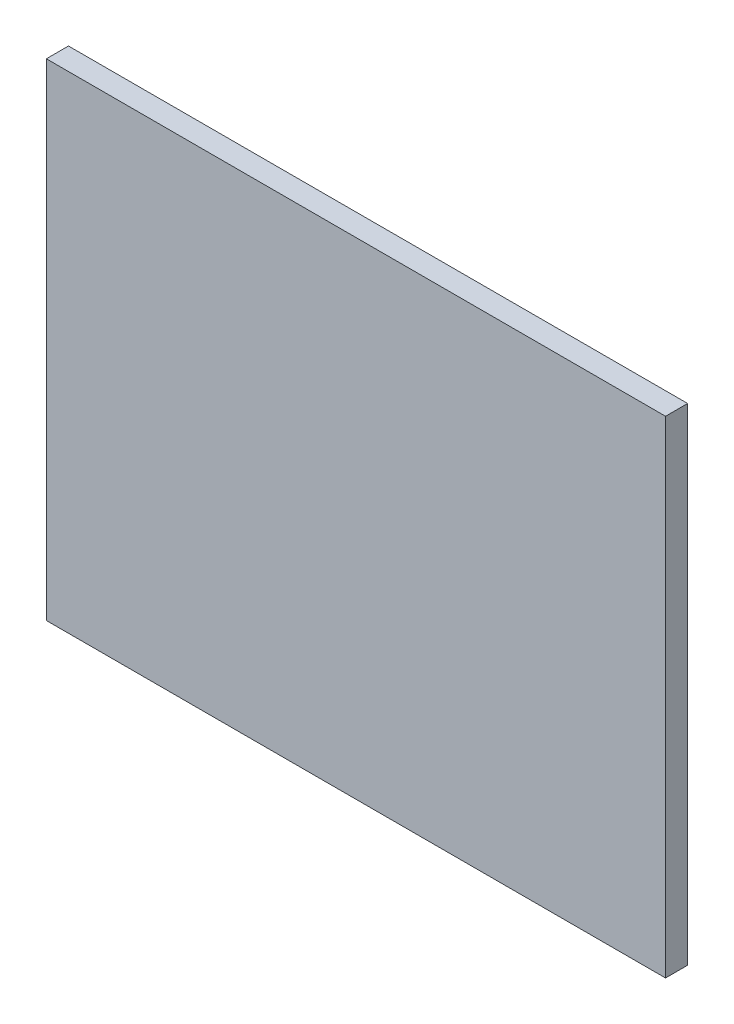
from build123d import *

# Parameters (mm, degrees)
SKETCH1_W           = 280
SKETCH1_H           = 220
BOSS_EXTRUDE1_DEPTH = 10


with BuildPart() as part:
    # Sketch1 → Boss-Extrude1 (new body)
    with BuildSketch(Plane.XY):
        with Locations((24.498480243, -12.036474164)):
            Rectangle(SKETCH1_W, SKETCH1_H)
    extrude(amount=BOSS_EXTRUDE1_DEPTH)


solid = part.part
